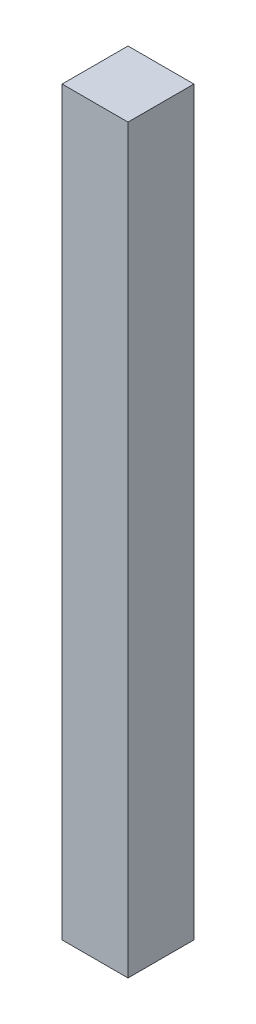
from build123d import *

# Parameters (mm, degrees)
SKETCH_1_W      = 40
SKETCH_1_H      = 40
EXTRUDE_1_DEPTH = 450


with BuildPart() as part:
    # Эскиз1 → Бобышка-Вытянуть1 (new body)
    with BuildSketch(Plane(origin=(0, 0, 0), x_dir=(1, 0, 0), z_dir=(0, 1, 0))):
        Rectangle(SKETCH_1_W, SKETCH_1_H)
    extrude(amount=EXTRUDE_1_DEPTH)


solid = part.part
